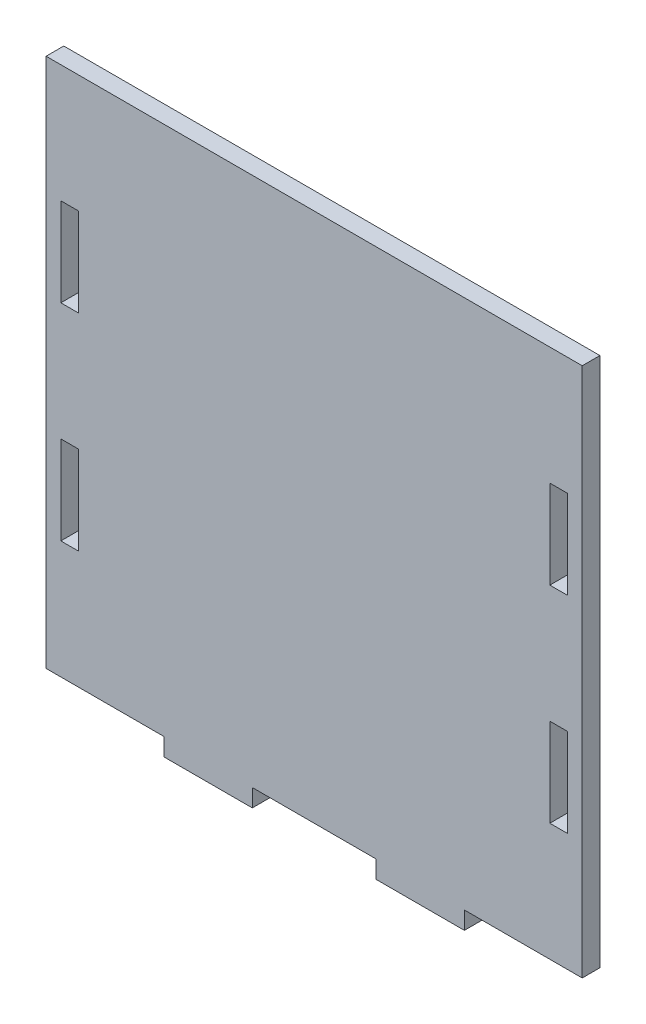
from build123d import *

# Parameters (mm, degrees)
SKETCH1_W           = 3
SKETCH1_H           = 15
BOSS_EXTRUDE1_DEPTH = 3


with BuildPart() as part:
    # Sketch1 → Boss-Extrude1 (new body)
    with BuildSketch(Plane.XY):
        Polygon((-45.5, 45), (-45.5, -45), (-25.5, -45), (-25.5, -48), (-10.5, -48), (-10.5, -45), (10.5, -45), (10.5, -48), (25.5, -48), (25.5, -45), (45.5, -45), (45.5, 45), align=None)
        with Locations((-41.5, -17.5)):
            Rectangle(SKETCH1_W, SKETCH1_H, mode=Mode.SUBTRACT)
        with Locations((41.5, -17.5)):
            Rectangle(SKETCH1_W, SKETCH1_H, mode=Mode.SUBTRACT)
        with Locations((-41.5, 17.5)):
            Rectangle(SKETCH1_W, SKETCH1_H, mode=Mode.SUBTRACT)
        with Locations((41.5, 17.5)):
            Rectangle(SKETCH1_W, SKETCH1_H, mode=Mode.SUBTRACT)
    extrude(amount=BOSS_EXTRUDE1_DEPTH)


solid = part.part
